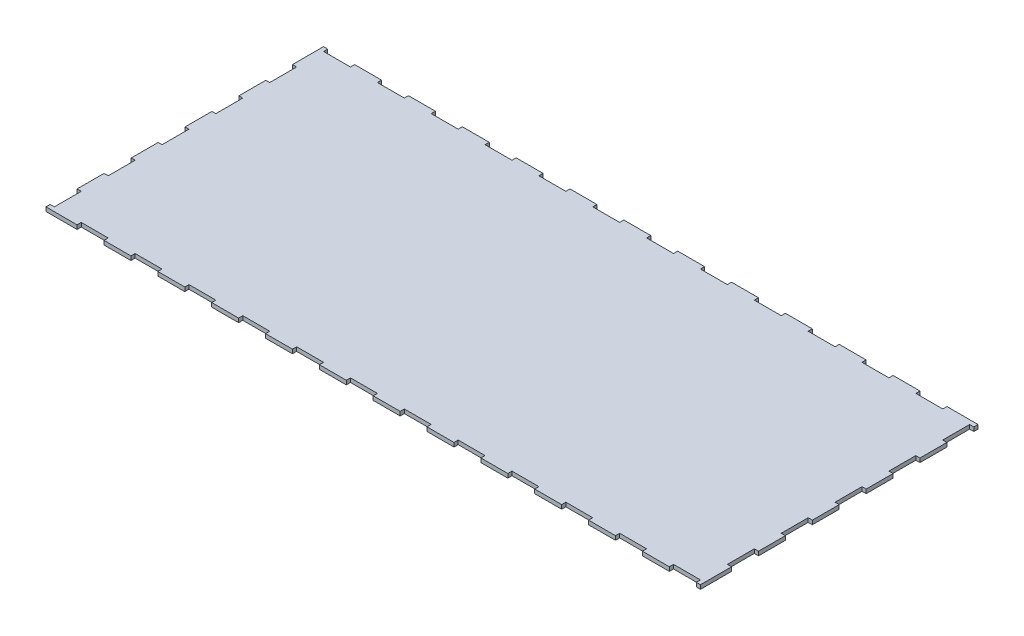
from build123d import *

# Parameters (mm, degrees)
SALIENTE_EXTRUIR1_DEPTH = 3


with BuildPart() as part:
    # Croquis1 → Saliente-Extruir1 (new body)
    with BuildSketch(Plane(origin=(0, 0, 0), x_dir=(1, 0, 0), z_dir=(0, 1, 0))):
        Polygon((0, 200), (0, 203.1), (-3.1, 203.1), (-3.1, 180), (0, 180), (0, 159.996339437), (-2.9, 159.996339437), (-2.9, 139.996339437), (0, 139.996339437), (0, 119.996339437), (-2.9, 119.996339437), (-2.9, 99.996339437), (0, 99.996339437), (0, 80), (-2.9, 80), (-2.9, 60), (0, 60), (0, 40), (-3.1, 40), (-3.1, 20), (0, 20), (0, 0), (-3.1, 0), (-3.1, -3.1), (20, -3.1), (20, 0), (40, 0), (40, -3.1), (60, -3.1), (60, 0), (80, 0), (80, -3.1), (100, -3.1), (100, 0), (120, 0), (120, -3.1), (140, -3.1), (140, 0), (160, 0), (160, -3.1), (180, -3.1), (180, 0), (200, 0), (200, -3.1), (220, -3.1), (220, 0), (240, 0), (240, -3.1), (260, -3.1), (260, 0), (280, 0), (280, -3.1), (300, -3.1), (300, 0), (320, 0), (320, -3.1), (340, -3.1), (340, 0), (360, 0), (360, -3.1), (380, -3.1), (380, 0), (400, 0), (400, -3.1), (420, -3.1), (420, 0), (440, 0), (440, -3.1), (460, -3.1), (460, 0), (480, 0), (480, -3.1), (483.1, -3.1), (483.1, 20), (480, 20), (480, 39.996339437), (483.1, 39.996339437), (483.1, 60), (480, 60), (480, 79.996339437), (483.1, 79.996339437), (483.1, 100), (480, 100), (480, 119.996339437), (483.1, 119.996339437), (483.1, 140), (480, 140), (480, 159.996339437), (483.1, 159.996339437), (483.1, 180), (480, 180), (480, 200), (483.1, 200), (483.1, 203.1), (460, 203.1), (460, 200), (440, 200), (440, 203.1), (420, 203.1), (420, 200), (400, 200), (400, 203.1), (380, 203.1), (380, 200), (360, 200), (360, 203.1), (340, 203.1), (340, 200), (320, 200), (320, 203.1), (300, 203.1), (300, 200), (280, 200), (280, 203.1), (260, 203.1), (260, 200), (240, 200), (240, 203.1), (220, 203.1), (220, 200), (200, 200), (200, 203.1), (180, 203.1), (180, 200), (160, 200), (160, 203.1), (140, 203.1), (140, 200), (120, 200), (120, 203.1), (100, 203.1), (100, 200), (80, 200), (80, 203.1), (60, 203.1), (60, 200), (40, 200), (40, 203.1), (20, 203.1), (20, 200), align=None)
    extrude(amount=SALIENTE_EXTRUIR1_DEPTH)


solid = part.part
